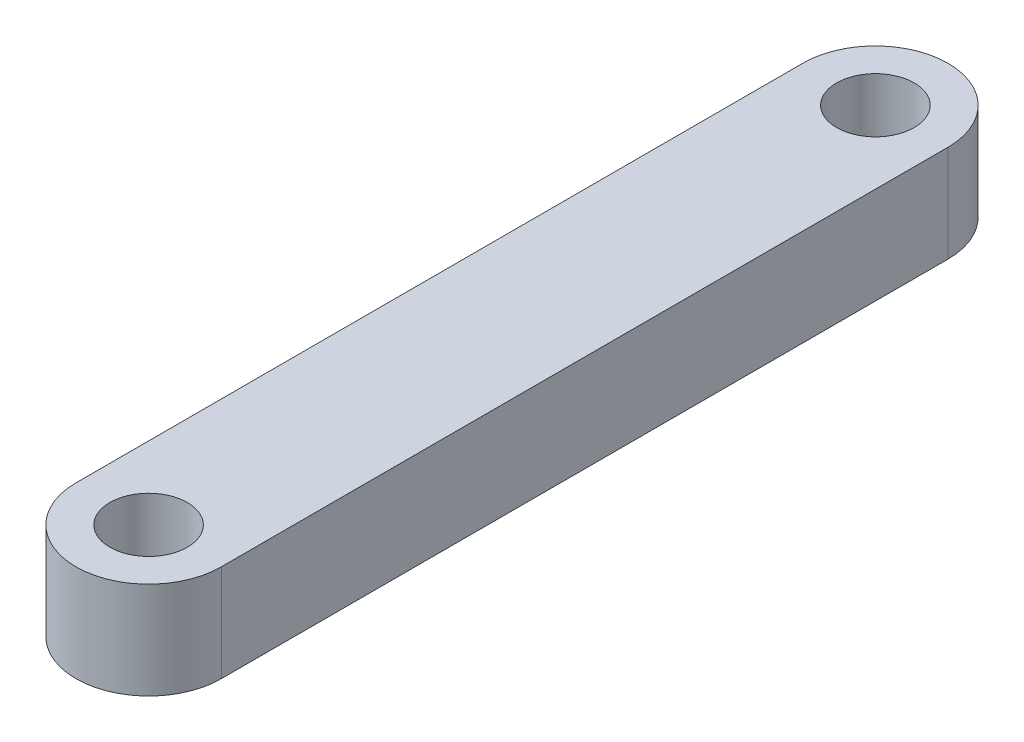
from build123d import *

# Parameters (mm, degrees)
SKETCH1_R           = 0.8
BOSS_EXTRUDE1_DEPTH = 2


with BuildPart() as part:
    # Sketch1 → Boss-Extrude1 (new body)
    with BuildSketch(Plane(origin=(0, 0, 0), x_dir=(1, 0, 0), z_dir=(0, 1, 0))):
        with BuildLine():
            Line((-1.5, 7.5), (-1.5, -7.5))
            ThreePointArc((-1.5, -7.5), (0, -9), (1.5, -7.5))
            Line((1.5, -7.5), (1.5, 7.5))
            ThreePointArc((1.5, 7.5), (0, 9), (-1.5, 7.5))
        make_face()
        with Locations((0, 7.5)):
            Circle(SKETCH1_R, mode=Mode.SUBTRACT)
        with Locations((0, -7.5)):
            Circle(SKETCH1_R, mode=Mode.SUBTRACT)
    extrude(amount=BOSS_EXTRUDE1_DEPTH)


solid = part.part
